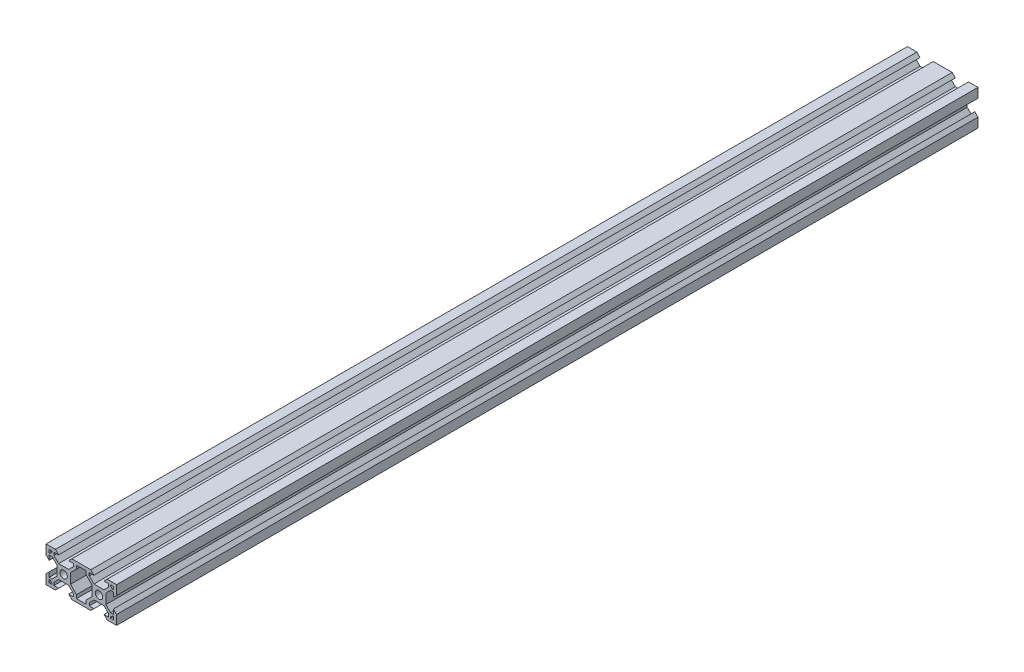
from build123d import *

# Parameters (mm, degrees)
SKETCH1_R           = 2.1
BOSS_EXTRUDE1_DEPTH = 488


with BuildPart() as part:
    # Sketch1 → Boss-Extrude1 (new body)
    with BuildSketch(Plane.XY):
        Polygon((0, 0), (0, 5.36), (1.8, 7.16), (1.8, 4.500660172), (3.44, 4.500660172), (6.099339828, 7.16), (6.099339828, 12.84), (3.44, 15.499339828), (1.8, 15.499339828), (1.8, 12.84), (0, 14.64), (0, 20), (5.36, 20), (7.16, 18.2), (4.500660172, 18.2), (4.500660172, 16.56), (7.16, 13.900660172), (12.84, 13.900660172), (15.499339828, 16.56), (15.499339828, 18.2), (12.84, 18.2), (14.64, 20), (20, 20), (25.36, 20), (27.16, 18.2), (24.500939946, 18.2), (24.50125838, 16.559689577), (27.161114417, 13.900866058), (32.84111431, 13.901968719), (35.499937829, 16.561824756), (35.49961981, 18.2), (32.84, 18.2), (34.64, 20), (39.999930631, 20), (40.000970647, 14.642698508), (38.201320116, 12.842349107), (38.200803857, 15.501688885), (36.560803888, 15.501370511), (33.901980368, 12.841514474), (33.903083029, 7.161514581), (36.562939066, 4.502691062), (38.202939036, 4.503009436), (38.202422777, 7.162349214), (40.002772178, 5.362698683), (40.003813241, 0), (34.64, 0), (32.84, 1.8), (35.502803549, 1.8), (35.502484821, 3.441825004), (32.842628784, 6.100648523), (27.162628891, 6.099545862), (24.503805372, 3.439689825), (24.504123686, 1.8), (27.16, 1.8), (25.36, 0), (20, 0), (14.64, 0), (12.84, 1.8), (15.499339828, 1.8), (15.499339828, 3.44), (12.84, 6.099339828), (7.16, 6.099339828), (4.500660172, 3.44), (4.500660172, 1.8), (7.16, 1.8), (5.36, 0), align=None)
        with Locations((10, 10)):
            Circle(SKETCH1_R, mode=Mode.SUBTRACT)
        with Locations((30, 10)):
            Circle(SKETCH1_R, mode=Mode.SUBTRACT)
        Polygon((17.300660172, 3.76), (17.300660172, 1.8), (22.700660172, 1.8), (22.700660172, 3.76), (26.100660172, 7.16), (26.100660172, 12.84), (22.699339828, 16.24), (22.699339828, 18.2), (17.300660172, 18.2), (17.300660172, 16.24), (13.900660172, 12.84), (13.900660172, 7.16), align=None, mode=Mode.SUBTRACT)
        Polygon((1.8, 18.2), (3.430660172, 18.2), (3.430660172, 17.63), (2.37, 16.569339828), (1.8, 16.569339828), align=None, mode=Mode.SUBTRACT)
        Polygon((1.8, 3.430660172), (1.8, 1.8), (3.430660172, 1.8), (3.430660172, 2.37), (2.37, 3.430660172), align=None, mode=Mode.SUBTRACT)
        Polygon((38.2, 1.8), (36.569339828, 1.8), (36.569339828, 2.37), (37.63, 3.430660172), (38.2, 3.430660172), align=None, mode=Mode.SUBTRACT)
        Polygon((38.2, 16.569339828), (38.2, 18.2), (36.569339828, 18.2), (36.569339828, 17.63), (37.63, 16.569339828), align=None, mode=Mode.SUBTRACT)
    extrude(amount=-BOSS_EXTRUDE1_DEPTH)


solid = part.part
